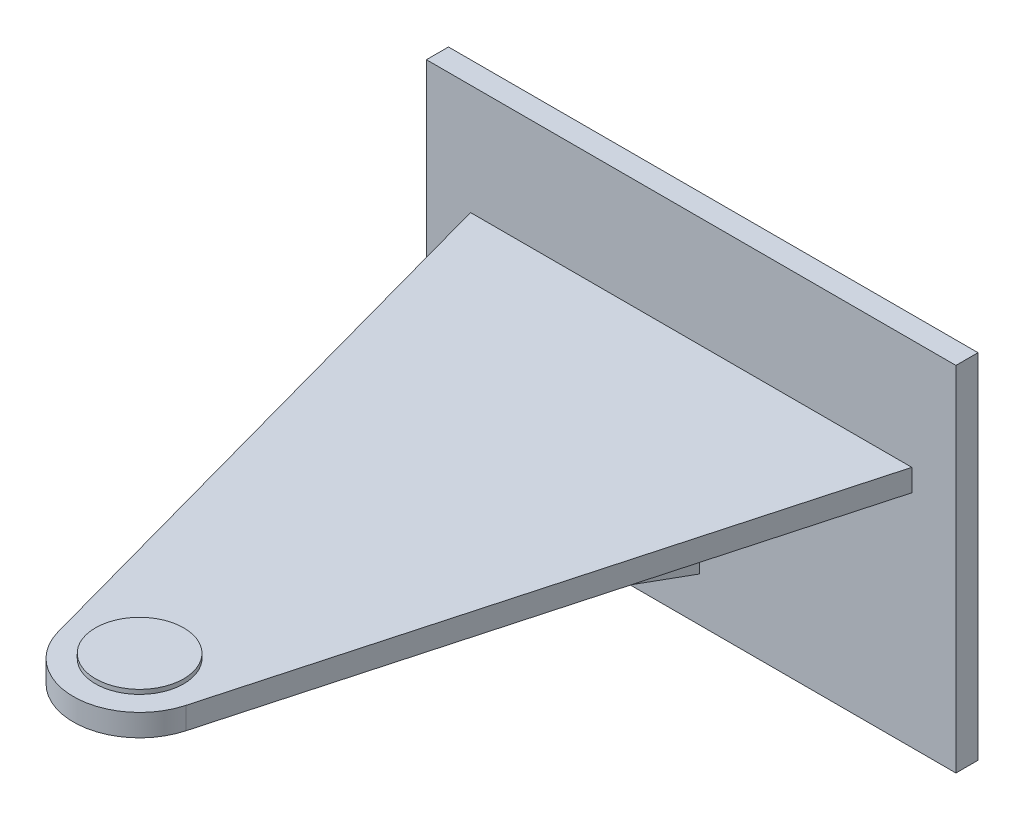
from build123d import *

# Parameters (mm, degrees)
SKETCH1_W      = 152.4
SKETCH1_H      = 101.6
EXTRUDE1_DEPTH = 6.35
EXTRUDE2_DEPTH = 6.35
SKETCH4_R      = 12.7
EXTRUDE3_DEPTH = 1.27
EXTRUDE4_DEPTH = 2.38125
RIB4_REACH     = 218.366
SKETCH8_WALL_W = 509.057660384
SKETCH8_WALL_H = 4.7625


with BuildPart() as part:
    # Sketch1 → Extrude1 (new body)
    with BuildSketch(Plane.XY):
        Rectangle(SKETCH1_W, SKETCH1_H)
    extrude(amount=EXTRUDE1_DEPTH)

    # Sketch3 → Extrude2 (add)
    with BuildSketch(Plane(origin=(0, 19.05, 0), x_dir=(-1, 0, 0), z_dir=(0, 1, 0))):
        with BuildLine():
            Line((63.5, 6.35), (18.365629617, 170.160251847))
            ThreePointArc((18.365629617, 170.160251847), (11.54349822, 180.254212248), (0, 184.15))
            ThreePointArc((0, 184.15), (-11.54349822, 180.254212248), (-18.365629617, 170.160251847))
            Line((-18.365629617, 170.160251847), (-63.5, 6.35))
            Line((-63.5, 6.35), (63.5, 6.35))
        make_face()
    extrude(amount=-EXTRUDE2_DEPTH)

    # Sketch4 → Extrude3 (add)
    with BuildSketch(Plane(origin=(0, 19.05, 0), x_dir=(-1, 0, 0), z_dir=(0, 1, 0))):
        with Locations(Location((0, 165.1, 0), (0, 0, 270))):
            Circle(SKETCH4_R)
    extrude(amount=EXTRUDE3_DEPTH)

    # Sketch5 → Extrude4 (add, symmetric)
    with BuildSketch(Plane(origin=(0, 0, 0), x_dir=(0, 0, -1), z_dir=(1, 0, 0))):
        Polygon((-146.05, 12.7), (-6.35, -38.1), (-6.35, 12.7), align=None)
    extrude(amount=EXTRUDE4_DEPTH, both=True)

    # Sketch8 wall → Rib4 (add, up to next)
    with BuildSketch(Plane(origin=(25.4, 0, 41.275), x_dir=(0, -0.341743063087, -0.939793423488), z_dir=(0, 0.939793423488, -0.341743063087)), mode=Mode.PRIVATE) as rib4_sk1:
        Rectangle(SKETCH8_WALL_W, SKETCH8_WALL_H)
    rib4_tool1 = extrude(rib4_sk1.sketch, amount=RIB4_REACH, mode=Mode.PRIVATE) - part.part
    add(rib4_tool1.solids().sort_by_distance((25.4, 0, 41.275))[0])


solid = part.part
